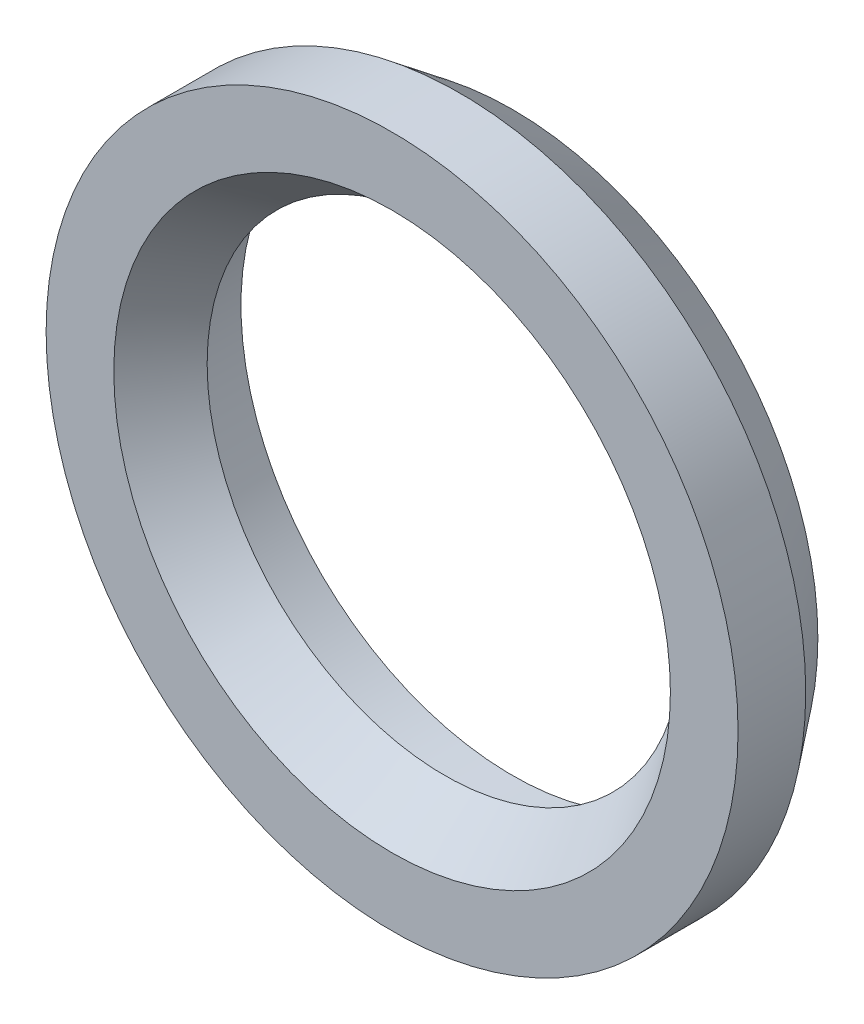
from build123d import *


with BuildPart() as part:
    # Sketch3 → Revolve1 (revolve)
    with BuildSketch(Plane(origin=(0, 0, 0), x_dir=(1, 0, 0), z_dir=(0, 1, 0))):
        Polygon((40.125, 0), (40.125, 10), (45.125, 10), (51.125, 2.205121208), (51.125, -7.794878792), (41.125, -7.794878792), (35.125, 0), align=None)
    revolve(axis=Axis((0, 0, 0), (0, 0, -1)))


solid = part.part
